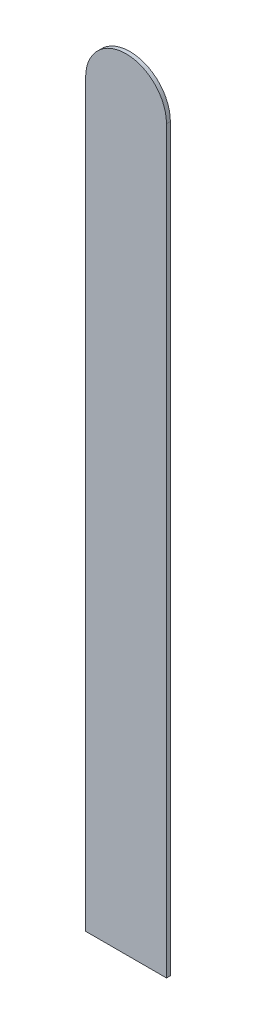
from build123d import *

# Parameters (mm, degrees)
BOSS_EXTRUDE1_DEPTH = 0.3048


with BuildPart() as part:
    # Sketch2 → Boss-Extrude1 (new body)
    with BuildSketch(Plane.XY):
        with BuildLine():
            Line((0, 70.6374), (0, 12.5222))
            Line((0, 12.5222), (-6.35, 12.5222))
            Line((-6.35, 12.5222), (-6.35, 70.6374))
            ThreePointArc((-6.35, 70.6374), (-3.175, 73.8124), (0, 70.6374))
        make_face()
    extrude(amount=BOSS_EXTRUDE1_DEPTH)


solid = part.part
